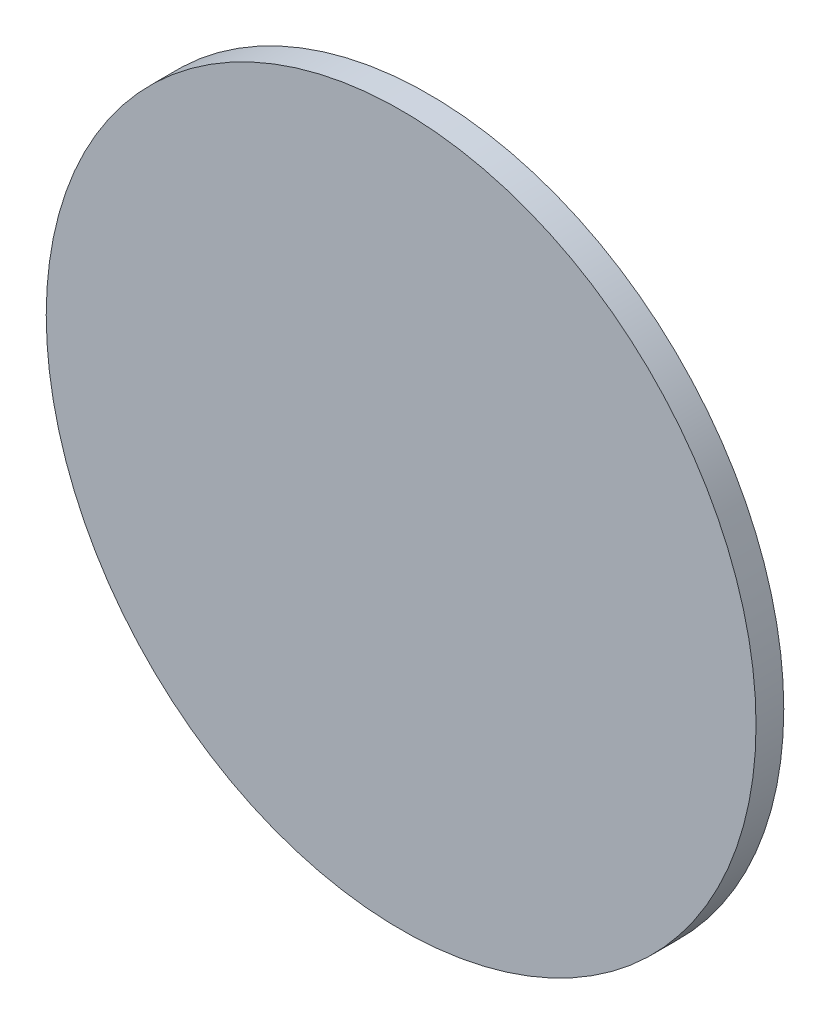
from build123d import *

# Parameters (mm, degrees)
SKETCH1_R           = 128
BOSS_EXTRUDE1_DEPTH = 10


with BuildPart() as part:
    # Sketch1 → Boss-Extrude1 (new body)
    with BuildSketch(Plane.XY):
        Circle(SKETCH1_R)
    extrude(amount=BOSS_EXTRUDE1_DEPTH)


solid = part.part
